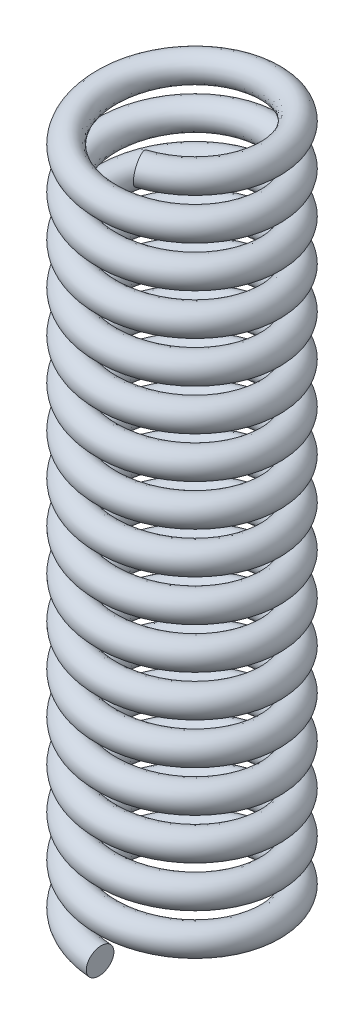
from build123d import *

# Parameters (mm, degrees)
SWEEP1_PITCH  = 6
SWEEP1_HEIGHT = 101.6
SWEEP1_RADIUS = 11.9
SKETCH2_R     = 2


with BuildPart() as part:
    # Sweep1: sweep along a helix
    with BuildLine() as sweep1_path:
        Helix(SWEEP1_PITCH, SWEEP1_HEIGHT, SWEEP1_RADIUS, center=(0, 0, 0), direction=(0, 1, 0), lefthand=True)
    # Sketch2 → Sweep1 (sweep)
    with BuildSketch(Plane(origin=(4.840166053, 101.6, 10.871190946), x_dir=(0.332224773, -0.441768862, 0.83334685), z_dir=(-0.910618222, 0.07998906, 0.405433354))):
        Circle(SKETCH2_R)
    sweep(path=sweep1_path.line, is_frenet=True)


solid = part.part
